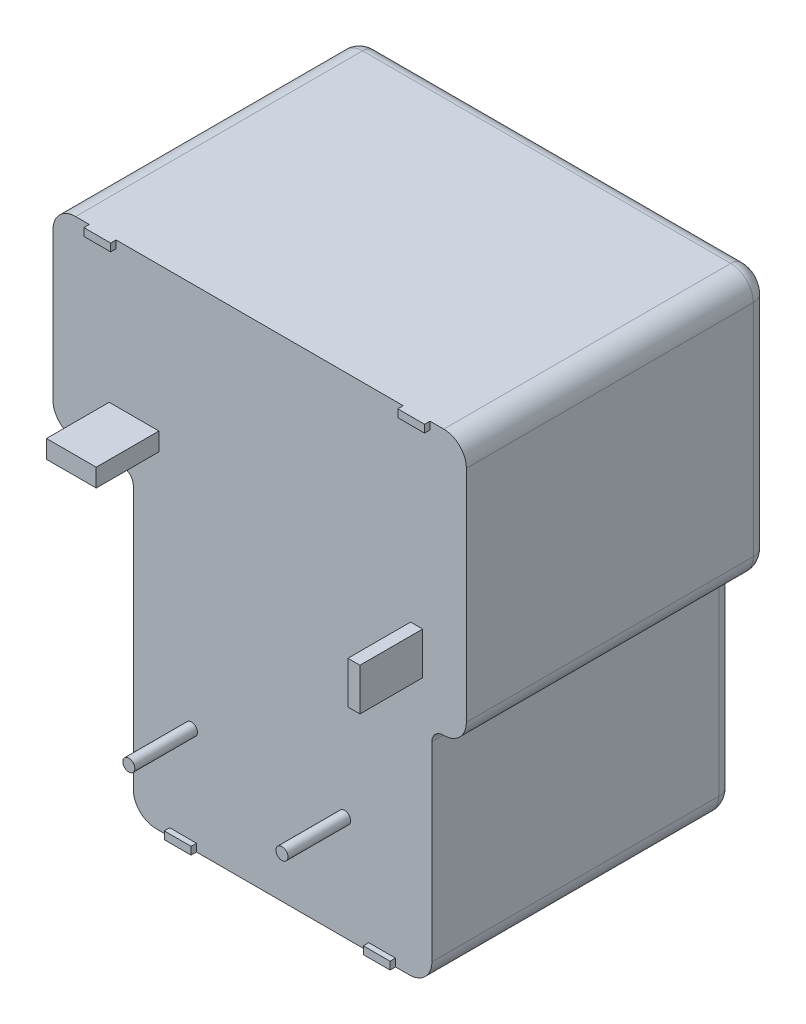
from build123d import *

# Parameters (mm, degrees)
SKETCH1_W           = 27.43
SKETCH1_H           = 32.51
BOSS_EXTRUDE1_DEPTH = 20.0406
SKETCH2_W           = 5.332
SKETCH2_H           = 19.71
CUT_EXTRUDE1_DEPTH  = 21.0406
SKETCH3_W           = 2.286
SKETCH3_H           = 14.91
CUT_EXTRUDE2_DEPTH  = 21.0406
SKETCH4_W           = 3.3
SKETCH4_H           = 1.2
BOSS_EXTRUDE2_DEPTH = 4.1594
SKETCH5_W           = 0.8
SKETCH5_H           = 2.8
BOSS_EXTRUDE3_DEPTH = 4.1594
SKETCH6_R           = 0.4
BOSS_EXTRUDE4_DEPTH = 4.1594
SKETCH7_W           = 1.778
SKETCH7_H           = 0.508
BOSS_EXTRUDE5_DEPTH = 0.3594
SKETCH8_W           = 1.778
SKETCH8_H           = 0.508
BOSS_EXTRUDE6_DEPTH = 0.3594
SKETCH9_W           = 1.778
SKETCH9_H           = 0.508
BOSS_EXTRUDE7_DEPTH = 0.3594
SKETCH10_W          = 1.778
SKETCH10_H          = 0.508
BOSS_EXTRUDE8_DEPTH = 0.3594
SKETCH11_R          = 0.4
BOSS_EXTRUDE9_DEPTH = 4.1594
FILLET1_R           = 1.500124
FILLET2_R           = 0.762
FILLET3_R           = 0.999998


with BuildPart() as part:
    # Sketch1 → Boss-Extrude1 (new body)
    with BuildSketch(Plane(origin=(0, 0, -20.0406), x_dir=(-1, 0, 0), z_dir=(0, 0, -1))):
        with Locations((0.4582, 0)):
            Rectangle(SKETCH1_W, SKETCH1_H)
    extrude(amount=-BOSS_EXTRUDE1_DEPTH)

    # Sketch2 → Cut-Extrude1 (cut, through all)
    with BuildSketch(Plane.XY):
        with Locations((-11.5072, -6.4)):
            Rectangle(SKETCH2_W, SKETCH2_H)
    extrude(amount=-CUT_EXTRUDE1_DEPTH, mode=Mode.SUBTRACT)

    # Sketch3 → Cut-Extrude2 (cut, through all)
    with BuildSketch(Plane.XY):
        with Locations((12.1138, -8.8)):
            Rectangle(SKETCH3_W, SKETCH3_H)
    extrude(amount=-CUT_EXTRUDE2_DEPTH, mode=Mode.SUBTRACT)

    # Sketch7 → Boss-Extrude5 (add)
    with BuildSketch(Plane.XY):
        with Locations((9.9548, 16.001)):
            Rectangle(SKETCH7_W, SKETCH7_H)
    extrude(amount=BOSS_EXTRUDE5_DEPTH)

    # Sketch8 → Boss-Extrude6 (add)
    with BuildSketch(Plane.XY):
        with Locations((-10.8712, 16.001)):
            Rectangle(SKETCH8_W, SKETCH8_H)
    extrude(amount=BOSS_EXTRUDE6_DEPTH)

    # Sketch9 → Boss-Extrude7 (add)
    with BuildSketch(Plane.XY):
        with Locations((-5.5392, -16.001)):
            Rectangle(SKETCH9_W, SKETCH9_H)
    extrude(amount=BOSS_EXTRUDE7_DEPTH)

    # Sketch10 → Boss-Extrude8 (add)
    with BuildSketch(Plane.XY):
        with Locations((7.6688, -16.001)):
            Rectangle(SKETCH10_W, SKETCH10_H)
    extrude(amount=BOSS_EXTRUDE8_DEPTH)

    # Fillet1
    fillet1_edges = [part.edges().sort_by_distance(p)[0] for p in [
        (-8.8412, -16.255, -10.0203),
        (-14.1732, 3.455, -10.0203),
        (13.2568, -1.345, -10.0203),
        (10.9708, -16.255, -10.0203),
        (-14.1732, 16.255, -10.0203),
        (13.2568, 16.255, -10.0203),
    ]]
    fillet(fillet1_edges, radius=FILLET1_R)

    # Fillet2
    fillet2_edges = [part.edges().sort_by_distance(p)[0] for p in [
        (-8.8412, 3.455, -10.0203),
        (10.9708, -1.345, -10.0203),
    ]]
    fillet(fillet2_edges, radius=FILLET2_R)

    # Fillet3
    fillet3_edges = [part.edges().sort_by_distance(p)[0] for p in [
        (-8.8412, -6.030938, -20.0406),
        (-14.1732, 9.855, -20.0406),
        (-0.4582, 16.255, -20.0406),
        (13.2568, 7.455, -20.0406),
        (11.744738, -1.345, -20.0406),
        (-13.733823853, 3.894376147, -20.0406),
        (-8.401823853, -15.815623853, -20.0406),
        (-13.733823853, 15.815623853, -20.0406),
        (12.817423853, -0.905623853, -20.0406),
        (12.817423853, 15.815623853, -20.0406),
        (10.531423853, -15.815623853, -20.0406),
        (10.9708, -8.430938, -20.0406),
        (-11.138138, 3.455, -20.0406),
        (11.193984633, -1.568184633, -20.0406),
        (-9.064384633, 3.231815367, -20.0406),
        (1.0648, -16.255, -20.0406),
    ]]
    fillet(fillet3_edges, radius=FILLET3_R)


with BuildPart() as body_2:
    # Sketch4 → Boss-Extrude2 (new body)
    with BuildSketch(Plane.XY):
        with Locations((-8.7932, 6.095)):
            Rectangle(SKETCH4_W, SKETCH4_H)
    extrude(amount=BOSS_EXTRUDE2_DEPTH)


with BuildPart() as body_3:
    # Sketch5 → Boss-Extrude3 (new body)
    with BuildSketch(Plane.XY):
        with Locations((9.9568, 2.665)):
            Rectangle(SKETCH5_W, SKETCH5_H)
    extrude(amount=BOSS_EXTRUDE3_DEPTH)


with BuildPart() as body_4:
    # Sketch6 → Boss-Extrude4 (new body)
    with BuildSketch(Plane.XY):
        with Locations((-4.9832, -9.345)):
            Circle(SKETCH6_R)
    extrude(amount=BOSS_EXTRUDE4_DEPTH)


with BuildPart() as body_5:
    # Sketch11 → Boss-Extrude9 (new body)
    with BuildSketch(Plane.XY):
        with Locations((5.1768, -9.345)):
            Circle(SKETCH11_R)
    extrude(amount=BOSS_EXTRUDE9_DEPTH)


solid = Compound([part.part, body_2.part, body_3.part, body_4.part, body_5.part])
